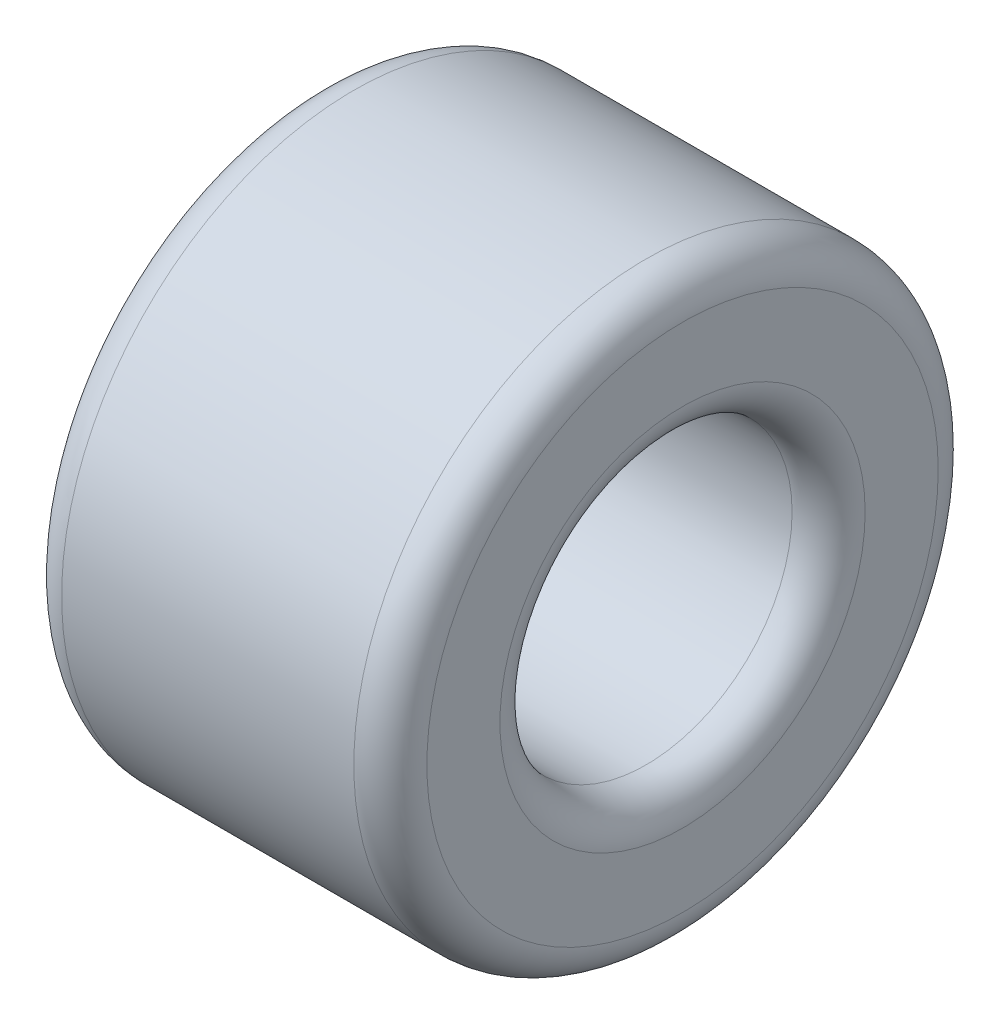
from build123d import *

# Parameters (mm, degrees)
SKETCH_1_R      = 8
SKETCH_1_R_2    = 4
EXTRUDE_1_DEPTH = 5
FILLET_1_R      = 1


with BuildPart() as part:
    # 草图1 → 凸台-拉伸1 (new body, symmetric)
    with BuildSketch(Plane(origin=(0, 0, 0), x_dir=(0, 0, -1), z_dir=(1, 0, 0))):
        Circle(SKETCH_1_R)
        Circle(SKETCH_1_R_2, mode=Mode.SUBTRACT)
    extrude(amount=EXTRUDE_1_DEPTH, both=True)

    # 圆角1
    fillet_1_edges = [part.edges().sort_by_distance(p)[0] for p in [
        (-5, 0, 8),
        (5, 0, 8),
        (-5, 0, 4),
        (5, 0, 4),
    ]]
    fillet(fillet_1_edges, radius=FILLET_1_R)


solid = part.part
